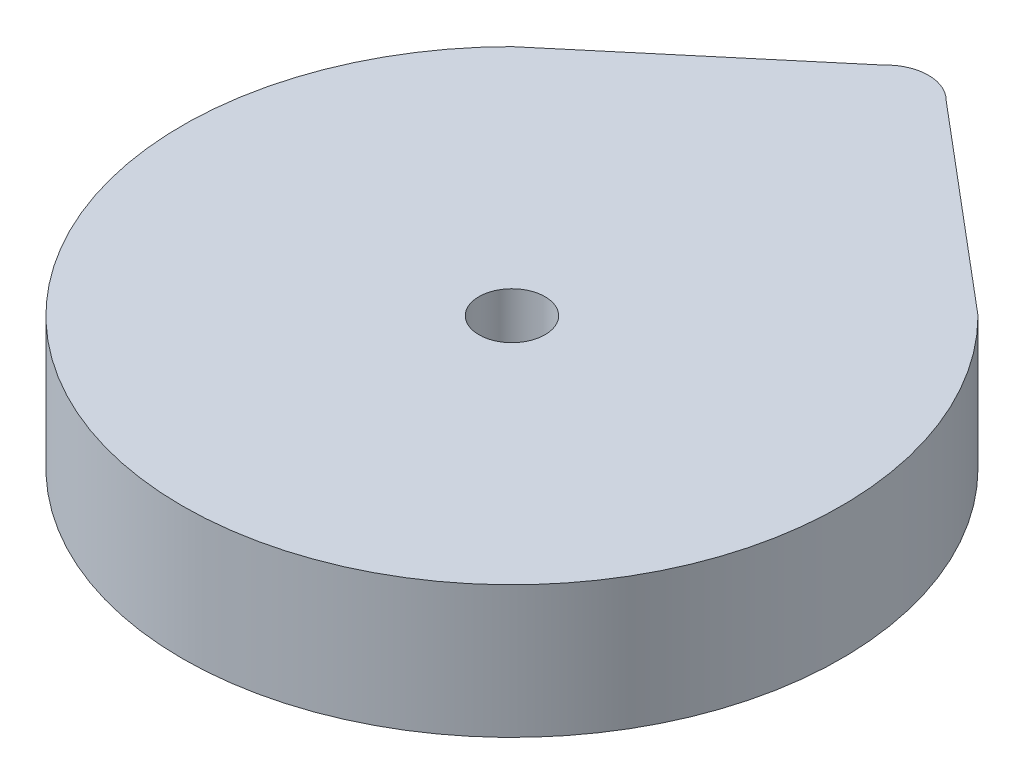
from build123d import *

# Parameters (mm, degrees)
SKETCH1_R           = 1.27
BOSS_EXTRUDE2_DEPTH = 5.08


with BuildPart() as part:
    # Sketch1 → Boss-Extrude2 (new body)
    with BuildSketch(Plane(origin=(0, 0, 0), x_dir=(1, 0, 0), z_dir=(0, 1, 0))):
        with BuildLine():
            Line((-8.953988524, 8.953988524), (-1.208326736, 15.472743004))
            ThreePointArc((-1.208326736, 15.472743004), (-0.025328041, 16.00445947), (1.173542757, 15.50956845))
            Line((1.173542757, 15.50956845), (8.953988524, 8.953988524))
            ThreePointArc((8.953988524, 8.953988524), (0, -12.662852008), (-8.953988524, 8.953988524))
        make_face()
        Circle(SKETCH1_R, mode=Mode.SUBTRACT)
    extrude(amount=BOSS_EXTRUDE2_DEPTH)


solid = part.part
